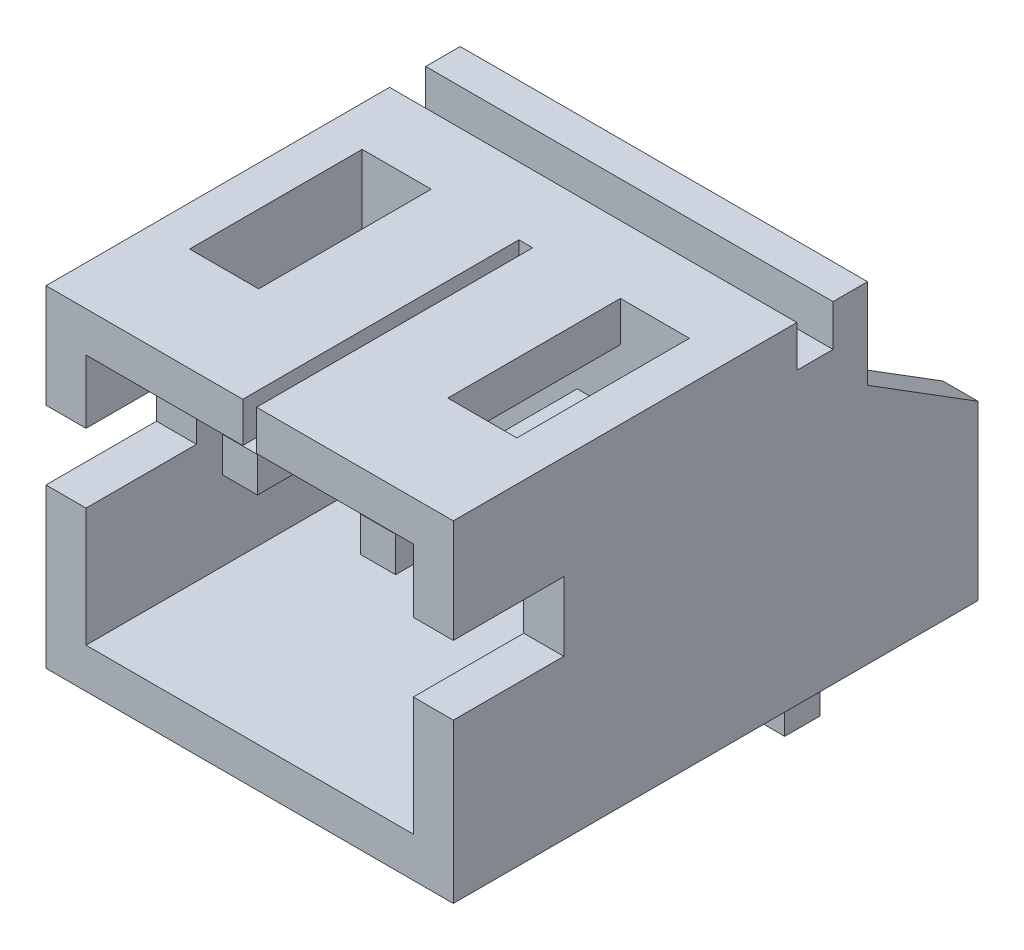
from build123d import *

# Parameters (mm, degrees)
SKETCH4_W                      = 5.9
SKETCH4_H                      = 4.8
BODY_EXTRUDE2_DEPTH            = 6
BODY_SHELL1_T                  = -0.58
BODY_SHELL1_THICKNESS_2_FACE_W = 4.74
BODY_SHELL1_THICKNESS_2_FACE_H = 3.64
BODY_SHELL1_THICKNESS_2_DEPTH  = 1.42
EXTRUDE1_REACH                 = 9.906
SKETCH66_W                     = 0.2
SKETCH66_H                     = 4
SKETCH66_W_2                   = 1
SKETCH66_H_2                   = 2.5
TAB_EXTRUDE4_DEPTH             = 0.508
TAB_EXTRUDE7_DEPTH             = 0.508
SKETCH64_W                     = 0.508
SKETCH64_H                     = 0.508
PINS_LPATTERN_COUNT            = 2
PINS_LPATTERN_PITCH            = 2
SKETCH67_W                     = 1.6
SKETCH67_H                     = 1
CUT_EXTRUDE2_DEPTH             = 1
SKETCH68_W                     = 5.9
SKETCH68_H                     = 0.52338994
CUT_EXTRUDE3_DEPTH             = 0.6


with BuildPart() as part:
    # Sketch4 → Body-Extrude2 (new body)
    with BuildSketch(Plane(origin=(6.86422654, -1.863703399, 0), x_dir=(1, 0, 0), z_dir=(0, 0, 1))):
        with Locations((-6.86422654, 1.863703399)):
            Rectangle(SKETCH4_W, SKETCH4_H)
    extrude(amount=BODY_EXTRUDE2_DEPTH)

    # Body-Shell1
    body_shell1_openings = [part.faces().sort_by_distance(p)[0] for p in [
        (0, 0, 6),
    ]]
    offset(amount=BODY_SHELL1_T, openings=body_shell1_openings, kind=Kind.INTERSECTION)

    # Body-Shell1 thickness 2 face (on inner face of the shell) → Body-Shell1 thickness 2 (add)
    with BuildSketch(Plane(origin=(0, 0, 0.58), x_dir=(-1, 0, 0), z_dir=(0, 0, -1))):
        Rectangle(BODY_SHELL1_THICKNESS_2_FACE_W, BODY_SHELL1_THICKNESS_2_FACE_H)
    extrude(amount=-BODY_SHELL1_THICKNESS_2_DEPTH)

    # Sketch66 → Extrude1 (cut, up to next)
    with BuildSketch(Plane(origin=(0, 1.82, 0), x_dir=(1, 0, 0), z_dir=(0, 1, 0)), mode=Mode.PRIVATE) as extrude1_sk1:
        with Locations((0, -4)):
            Rectangle(SKETCH66_W, SKETCH66_H)
    extrude1_tool1 = extrude(extrude1_sk1.sketch, amount=EXTRUDE1_REACH, mode=Mode.PRIVATE) & part.part
    # Sketch66 → Extrude1 (cut, up to next)
    with BuildSketch(Plane(origin=(0, 1.82, 0), x_dir=(1, 0, 0), z_dir=(0, 1, 0)), mode=Mode.PRIVATE) as extrude1_sk2:
        with Locations((-1.87, -3.25)):
            Rectangle(SKETCH66_W_2, SKETCH66_H_2)
    extrude1_tool2 = extrude(extrude1_sk2.sketch, amount=EXTRUDE1_REACH, mode=Mode.PRIVATE) & part.part
    # Sketch66 → Extrude1 (cut, up to next)
    with BuildSketch(Plane(origin=(0, 1.82, 0), x_dir=(1, 0, 0), z_dir=(0, 1, 0)), mode=Mode.PRIVATE) as extrude1_sk3:
        with Locations((1.87, -3.25)):
            Rectangle(SKETCH66_W_2, SKETCH66_H_2)
    extrude1_tool3 = extrude(extrude1_sk3.sketch, amount=EXTRUDE1_REACH, mode=Mode.PRIVATE) & part.part
    add(extrude1_tool1.solids().sort_by_distance((0, 1.82, 4))[0], mode=Mode.SUBTRACT)
    add(extrude1_tool2.solids().sort_by_distance((-1.87, 1.82, 3.25))[0], mode=Mode.SUBTRACT)
    add(extrude1_tool3.solids().sort_by_distance((1.87, 1.82, 3.25))[0], mode=Mode.SUBTRACT)

    # Sketch6 → Tab-Extrude4 (add)
    with BuildSketch(Plane(origin=(2.95, 11.117293973, 0), x_dir=(0, 0, -1), z_dir=(1, 0, 0))):
        Polygon((0, -10.017293973), (1.6, -11.017293973), (1.6, -13.517293973), (0, -13.517293973), align=None)
    extrude(amount=-TAB_EXTRUDE4_DEPTH)

    # Sketch9 → Tab-Extrude7 (add)
    with BuildSketch(Plane(origin=(-2.95, 11.117293973, 0), x_dir=(0, 0, 1), z_dir=(-1, 0, 0))):
        Polygon((0, -13.517293973), (0, -10.017293973), (-1.6, -11.017293973), (-1.6, -13.517293973), align=None)
    extrude(amount=-TAB_EXTRUDE7_DEPTH)


with BuildPart() as body_2:
    # Pins-Sweep: sweep along a path in Sketch65
    with BuildLine(Plane(origin=(0, 0, 0), x_dir=(0, 0, -1), z_dir=(1, 0, 0))) as pins_sweep_path:
        Line((-5.14, 0.7), (-0.25, 0.7))
        ThreePointArc((-0.25, 0.7), (0.457106781, 0.407106781), (0.75, -0.3))
        Line((0.75, -0.3), (0.75, -4.4))
    # Sketch64 → Pins-Sweep (sweep)
    with BuildSketch(Plane(origin=(0, 3.64, 5.14), x_dir=(1, 0, 0), z_dir=(0, 0, -1))):
        with Locations((-1, 2.94)):
            Rectangle(SKETCH64_W, SKETCH64_H)
    pins_sweep = sweep(path=pins_sweep_path.line)


with BuildPart() as part_1:
    add(part.part)

    # Pins-LPattern: Pins-Sweep ×2
    with Locations(*[(i * PINS_LPATTERN_PITCH, 0, 0) for i in range(1, PINS_LPATTERN_COUNT)]):
        add(pins_sweep)

    # Sketch67 → Cut-Extrude2 (cut)
    with BuildSketch(Plane(origin=(2.95, 0, 0), x_dir=(0, 0, -1), z_dir=(1, 0, 0))):
        with Locations((-5.2, 0.4)):
            Rectangle(SKETCH67_W, SKETCH67_H)
    cut_extrude2 = extrude(amount=-CUT_EXTRUDE2_DEPTH, mode=Mode.SUBTRACT)

    # Mirror1: Cut-Extrude2 across plane
    add(cut_extrude2.mirror(Plane(origin=(0, 0, 0), x_dir=(0, 0, 1), z_dir=(1, 0, 0))), mode=Mode.SUBTRACT)

    # Sketch68 → Cut-Extrude3 (cut)
    with BuildSketch(Plane(origin=(0, 2.4, 0), x_dir=(1, 0, 0), z_dir=(0, 1, 0))):
        with Locations((0, -0.76169497)):
            Rectangle(SKETCH68_W, SKETCH68_H)
    extrude(amount=-CUT_EXTRUDE3_DEPTH, mode=Mode.SUBTRACT)


solid = Compound([body_2.part, part_1.part])
